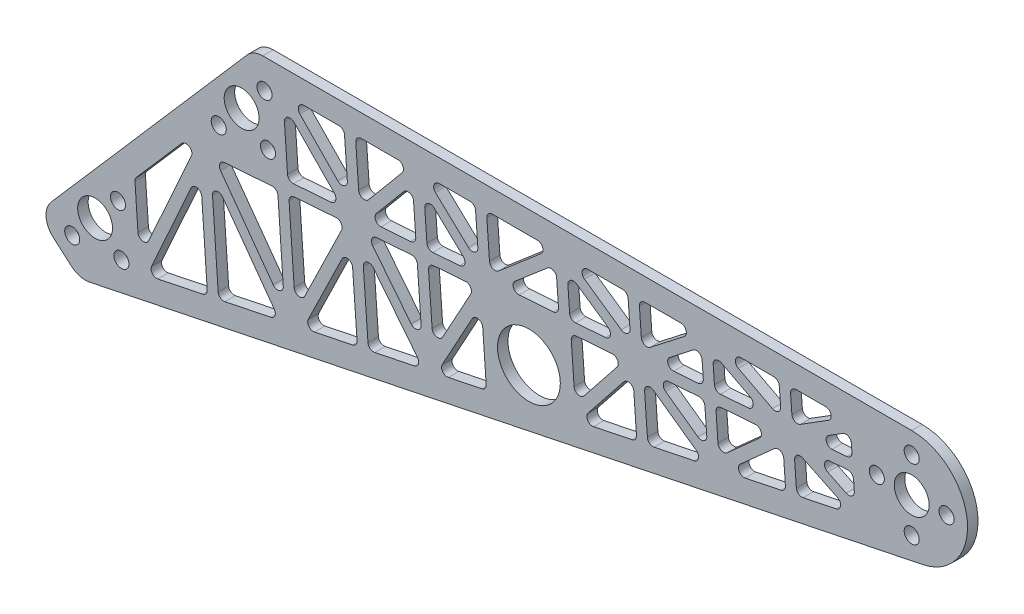
from build123d import *

# Parameters (mm, degrees)
SKETCH1_R           = 7.9375
SKETCH1_R_2         = 3.429
SKETCH1_R_3         = 14.2875
BOSS_EXTRUDE1_DEPTH = 4.7625
CUT_EXTRUDE2_DEPTH  = 5.7625
FILLET1_R           = 2.54


with BuildPart() as part:
    # Sketch1 → Boss-Extrude1 (new body)
    with BuildSketch(Plane.XY):
        with BuildLine():
            Line((304.8, 25.4), (9.593010709, 25.4))
            ThreePointArc((9.593010709, 25.4), (5.643057573, 24.542381105), (2.404401957, 22.123962251))
            Line((2.404401957, 22.123962251), (-86.655346099, -80.327558268))
            ThreePointArc((-86.655346099, -80.327558268), (-88.968534927, -87.240950932), (-85.715699599, -93.765129271))
            Line((-85.715699599, -93.765129271), (-77.389837916, -101.002690413))
            ThreePointArc((-77.389837916, -101.002690413), (-73.552808487, -103.028646494), (-69.21525712, -103.142405102))
            Line((-69.21525712, -103.142405102), (309.934982787, -24.875529176))
            ThreePointArc((309.934982787, -24.875529176), (330.068542113, 2.580848594), (304.8, 25.4))
        make_face()
        with Locations((304.8, 0)):
            Circle(SKETCH1_R, mode=Mode.SUBTRACT)
        Circle(SKETCH1_R, mode=Mode.SUBTRACT)
        with Locations((-66.655597345, -76.678493351)):
            Circle(SKETCH1_R, mode=Mode.SUBTRACT)
        with Locations((304.8, 15.875)):
            Circle(SKETCH1_R_2, mode=Mode.SUBTRACT)
        with Locations((320.675, 0)):
            Circle(SKETCH1_R_2, mode=Mode.SUBTRACT)
        with Locations((304.8, -15.875)):
            Circle(SKETCH1_R_2, mode=Mode.SUBTRACT)
        with Locations((288.925, 0)):
            Circle(SKETCH1_R_2, mode=Mode.SUBTRACT)
        with Locations((-56.24066026, -64.697478765)):
            Circle(SKETCH1_R_2, mode=Mode.SUBTRACT)
        with Locations((-54.674582759, -87.093430436)):
            Circle(SKETCH1_R_2, mode=Mode.SUBTRACT)
        with Locations((-77.070534431, -88.659507937)):
            Circle(SKETCH1_R_2, mode=Mode.SUBTRACT)
        with Locations((-10.414937085, -11.981014586)):
            Circle(SKETCH1_R_2, mode=Mode.SUBTRACT)
        with Locations((11.981014586, -10.414937085)):
            Circle(SKETCH1_R_2, mode=Mode.SUBTRACT)
        with Locations((10.414937085, 11.981014586)):
            Circle(SKETCH1_R_2, mode=Mode.SUBTRACT)
        with Locations((130.671295769, -35.944879509)):
            Circle(SKETCH1_R_3, mode=Mode.SUBTRACT)
    extrude(amount=BOSS_EXTRUDE1_DEPTH)

    # Sketch2 → Cut-Extrude2 (cut, through all)
    with BuildSketch(Plane.XY.offset(4.7625)):
        Polygon((-47.752387737, -64.103921212), (-46.456257203, -82.639451401), (-21.089738082, -26.326156287), (-26.6000281, -26.728229117), (-48.596517992, -52.032296158), align=None)
        Polygon((-18.852786296, -33.729027092), (-43.010514922, -87.35882529), (-15.499737704, -81.679855951), align=None)
        Polygon((-13.870444998, -32.155045072), (-10.479794672, -80.643603782), (17.161678338, -74.937655293), align=None)
        Polygon((16.340027274, -23.594994833), (-12.288563664, -25.683955405), (19.556084627, -69.586757695), align=None)
        Polygon((49.781991017, -28.066957817), (28.051714557, -72.689656944), (52.667232701, -67.608347474), align=None)
        Polygon((47.413555842, -21.327632945), (21.406580565, -23.225300422), (24.556066139, -68.265042494), align=None)
        Polygon((18.990703423, 11.323352307), (20.469287103, -9.821379443), (21.052216056, -18.157651855), (45.994204759, -16.337693929), align=None)
        Polygon((46.621984729, 15.24), (22.266489104, 15.24), (48.589481613, -11.723966776), align=None)
        Polygon((76.500439983, 15.24), (51.715490436, 15.24), (53.705240679, -12.02894253), align=None)
        Polygon((77.734498883, 8.795632856), (57.421576573, -15.503865635), (79.390606643, -13.900837469), align=None)
        Polygon((104.996737208, -12.032418682), (82.819961611, 8.90585952), (84.457136747, -13.53114475), align=None)
        Polygon((106.244089232, 15.24), (83.51088576, 15.24), (107.92611914, -7.811725741), align=None)
        Polygon((84.826829466, -18.597674854), (87.270405976, -52.086173042), (106.466791039, -17.018658038), align=None)
        Polygon((79.760299362, -18.967367573), (56.612566731, -20.656402877), (82.232322172, -52.845713943), align=None)
        Polygon((54.760173793, -26.486490935), (57.685155961, -66.572512241), (82.57556728, -61.434457376), align=None)
        Polygon((109.028431178, -22.918588384), (88.628342998, -60.185000575), (111.40460578, -55.483363214), (110.088517195, -37.446755808), align=None)
        Polygon((141.402736231, 15.24), (111.337594939, 15.24), (113.102778495, -8.951322047), align=None)
        Polygon((142.927838801, 9.860609466), (118.466281136, -11.049577918), (144.315974823, -9.163386906), align=None)
        Polygon((151.254074344, -34.443003217), (151.701842175, -40.579529803), (174.372401949, -12.063746212), (149.752197646, -13.860224291), align=None)
        Polygon((172.606779354, -7.09907381), (148.015436384, 9.941578563), (149.382504927, -8.793694187), align=None)
        Polygon((175.643104493, 15.24), (149.288321632, 15.24), (177.046653576, -3.995227848), align=None)
        Polygon((209.109688014, 10.322800424), (188.151398569, -5.96481971), (210.180866173, -4.35738156), align=None)
        Polygon((210.550558892, -9.423911664), (187.154313578, -11.131080351), (211.971631689, -28.899296858), align=None)
        Polygon((182.894173239, -14.328767595), (184.791733458, -40.334272927), (211.512529796, -34.818377033), align=None)
        Polygon((177.90665695, -15.781321426), (153.202390688, -46.855168633), (179.773810198, -41.370108161), align=None)
        Polygon((215.617088996, -9.054218945), (217.056031125, -28.77449809), (241.129872975, -7.192611438), align=None)
        Polygon((246.207930205, -9.462714657), (219.842695474, -33.098805278), (247.515774209, -27.386332511), align=None)
        Polygon((239.271634347, -2.234697008), (214.16266379, 10.87825122), (215.247396277, -3.987688841), align=None)
        Polygon((244.405431541, 15.24), (216.784600548, 15.24), (245.499668966, 0.24379756), align=None)
        Polygon((274.495124749, 15.24), (249.498937248, 15.24), (250.591053633, 0.272865787), align=None)
        Polygon((251.217737104, -8.315647075), (252.53369747, -26.350497278), (277.781525127, -21.138662003), align=None)
        Polygon((278.174218621, -4.489573149), (258.02327566, -5.959939798), (279.021121865, -16.096133293), align=None)
        Polygon((277.054985863, 10.849182993), (258.386222751, -0.8399507), (277.804525902, 0.576956955), align=None)
        Polygon((207.15833568, 15.24), (180.7366102, 15.24), (182.15448834, -4.19160335), align=None)
    extrude(amount=-CUT_EXTRUDE2_DEPTH, mode=Mode.SUBTRACT)

    # Fillet1
    fillet1_edges = [part.edges().sort_by_distance(p)[0] for p in [
        (250.591053633, 0.272865787, 2.38125),
        (249.498937248, 15.24, 2.38125),
        (274.495124749, 15.24, 2.38125),
        (251.217737104, -8.315647075, 2.38125),
        (277.781525127, -21.138662003, 2.38125),
        (252.53369747, -26.350497278, 2.38125),
        (279.021121865, -16.096133293, 2.38125),
        (258.02327566, -5.959939798, 2.38125),
        (278.174218621, -4.489573149, 2.38125),
        (258.386222751, -0.8399507, 2.38125),
        (277.054985863, 10.849182993, 2.38125),
        (277.804525902, 0.576956955, 2.38125),
        (214.16266379, 10.87825122, 2.38125),
        (239.271634347, -2.234697008, 2.38125),
        (215.247396277, -3.987688841, 2.38125),
        (245.499668966, 0.24379756, 2.38125),
        (216.784600548, 15.24, 2.38125),
        (244.405431541, 15.24, 2.38125),
        (217.056031125, -28.77449809, 2.38125),
        (215.617088996, -9.054218945, 2.38125),
        (241.129872975, -7.192611438, 2.38125),
        (247.515774209, -27.386332511, 2.38125),
        (219.842695474, -33.098805278, 2.38125),
        (246.207930205, -9.462714657, 2.38125),
        (148.015436384, 9.941578563, 2.38125),
        (172.606779354, -7.09907381, 2.38125),
        (149.382504927, -8.793694187, 2.38125),
        (177.046653576, -3.995227848, 2.38125),
        (149.288321632, 15.24, 2.38125),
        (175.643104493, 15.24, 2.38125),
        (151.701842175, -40.579529803, 2.38125),
        (149.752197646, -13.860224291, 2.38125),
        (174.372401949, -12.063746212, 2.38125),
        (118.466281136, -11.049577918, 2.38125),
        (142.927838801, 9.860609466, 2.38125),
        (144.315974823, -9.163386906, 2.38125),
        (177.90665695, -15.781321426, 2.38125),
        (179.773810198, -41.370108161, 2.38125),
        (153.202390688, -46.855168633, 2.38125),
        (182.894173239, -14.328767595, 2.38125),
        (211.512529796, -34.818377033, 2.38125),
        (184.791733458, -40.334272927, 2.38125),
        (210.550558892, -9.423911664, 2.38125),
        (211.971631689, -28.899296858, 2.38125),
        (187.154313578, -11.131080351, 2.38125),
        (210.180866173, -4.35738156, 2.38125),
        (188.151398569, -5.96481971, 2.38125),
        (209.109688014, 10.322800424, 2.38125),
        (24.556066139, -68.265042494, 2.38125),
        (21.406580565, -23.225300422, 2.38125),
        (47.413555842, -21.327632945, 2.38125),
        (18.990703423, 11.323352307, 2.38125),
        (45.994204759, -16.337693929, 2.38125),
        (21.052216056, -18.157651855, 2.38125),
        (22.266489104, 15.24, 2.38125),
        (46.621984729, 15.24, 2.38125),
        (48.589481613, -11.723966776, 2.38125),
        (53.705240679, -12.02894253, 2.38125),
        (51.715490436, 15.24, 2.38125),
        (76.500439983, 15.24, 2.38125),
        (-18.852786296, -33.729027092, 2.38125),
        (-15.499737704, -81.679855951, 2.38125),
        (-43.010514922, -87.35882529, 2.38125),
        (-13.870444998, -32.155045072, 2.38125),
        (17.161678338, -74.937655293, 2.38125),
        (-10.479794672, -80.643603782, 2.38125),
        (-12.288563664, -25.683955405, 2.38125),
        (16.340027274, -23.594994833, 2.38125),
        (19.556084627, -69.586757695, 2.38125),
        (49.781991017, -28.066957817, 2.38125),
        (52.667232701, -67.608347474, 2.38125),
        (28.051714557, -72.689656944, 2.38125),
        (113.102778495, -8.951322047, 2.38125),
        (111.337594939, 15.24, 2.38125),
        (141.402736231, 15.24, 2.38125),
        (109.028431178, -22.918588384, 2.38125),
        (111.40460578, -55.483363214, 2.38125),
        (88.628342998, -60.185000575, 2.38125),
        (79.760299362, -18.967367573, 2.38125),
        (82.232322172, -52.845713943, 2.38125),
        (56.612566731, -20.656402877, 2.38125),
        (54.760173793, -26.486490935, 2.38125),
        (82.57556728, -61.434457376, 2.38125),
        (57.685155961, -66.572512241, 2.38125),
        (57.421576573, -15.503865635, 2.38125),
        (77.734498883, 8.795632856, 2.38125),
        (79.390606643, -13.900837469, 2.38125),
        (84.457136747, -13.53114475, 2.38125),
        (82.819961611, 8.90585952, 2.38125),
        (104.996737208, -12.032418682, 2.38125),
        (107.92611914, -7.811725741, 2.38125),
        (83.51088576, 15.24, 2.38125),
        (106.244089232, 15.24, 2.38125),
        (87.270405976, -52.086173042, 2.38125),
        (84.826829466, -18.597674854, 2.38125),
        (106.466791039, -17.018658038, 2.38125),
        (182.15448834, -4.19160335, 2.38125),
        (180.7366102, 15.24, 2.38125),
        (207.15833568, 15.24, 2.38125),
        (-21.089738082, -26.326156287, 2.38125),
        (-46.456257203, -82.639451401, 2.38125),
        (-48.596517992, -52.032296158, 2.38125),
        (-26.6000281, -26.728229117, 2.38125),
    ]]
    fillet(fillet1_edges, radius=FILLET1_R)


solid = part.part
